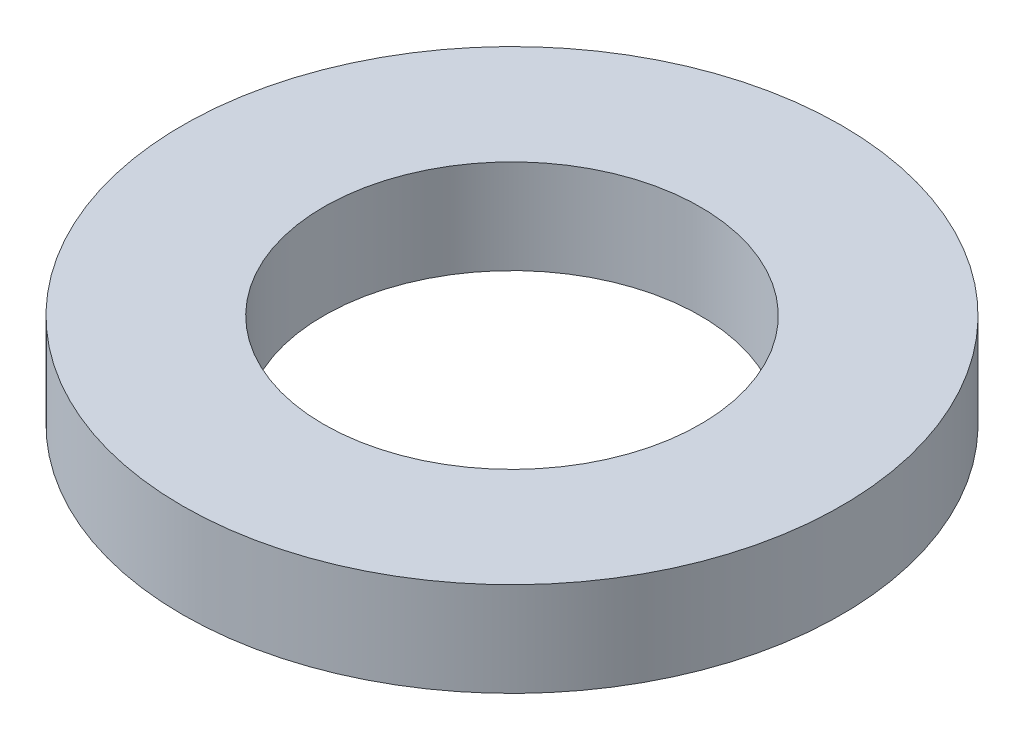
from build123d import *

# Parameters (mm, degrees)
SKETCH_1_R      = 7
SKETCH_1_R_2    = 4
EXTRUDE_1_DEPTH = 2


with BuildPart() as part:
    # Эскиз1 → Бобышка-Вытянуть1 (new body)
    with BuildSketch(Plane(origin=(0, 0, 0), x_dir=(1, 0, 0), z_dir=(0, 1, 0))):
        Circle(SKETCH_1_R)
        Circle(SKETCH_1_R_2, mode=Mode.SUBTRACT)
    extrude(amount=EXTRUDE_1_DEPTH)


solid = part.part
